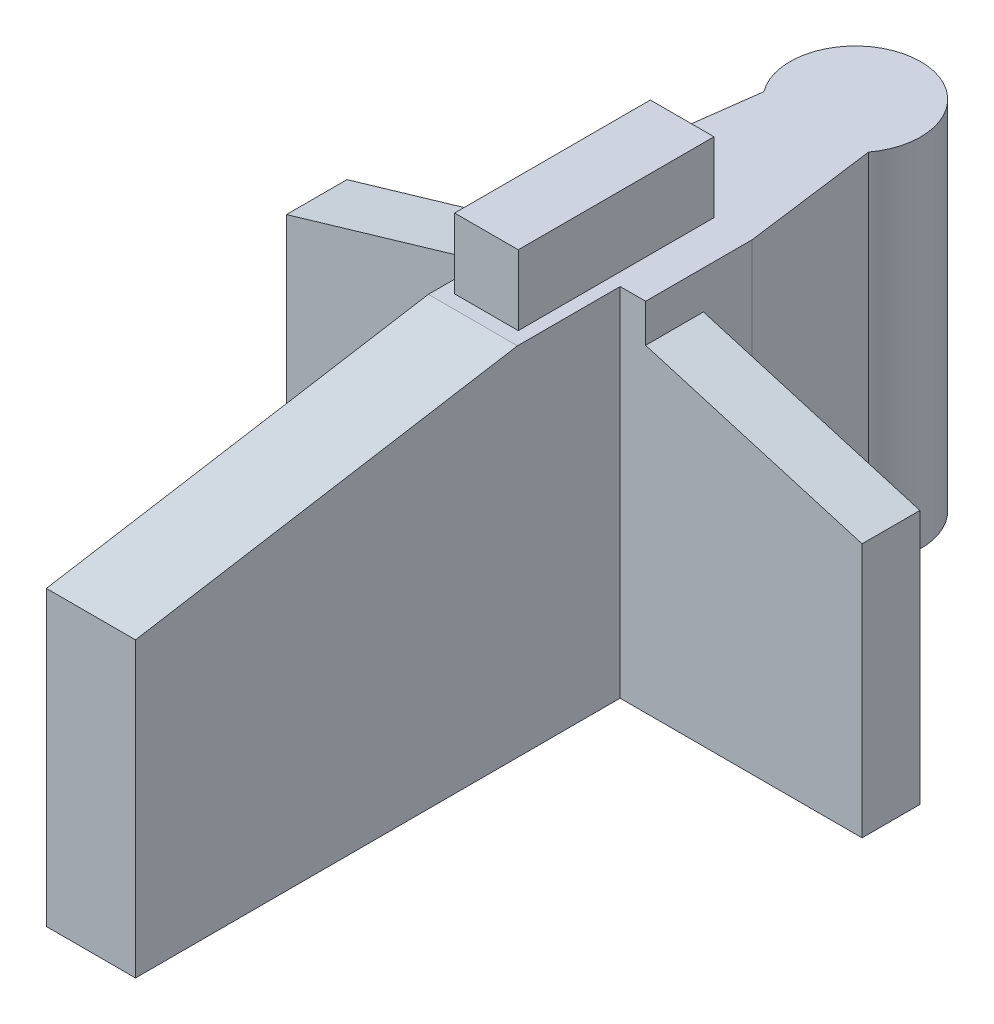
from build123d import *

# Parameters (mm, degrees)
BOSS_EXTRUDE1_DEPTH = 28
BOSS_EXTRUDE2_DEPTH = 5.5
CUT_EXTRUDE1_DEPTH  = 5.5
CUT_EXTRUDE2_DEPTH  = 8


with BuildPart() as part:
    # Sketch2 → Boss-Extrude1 (new body)
    with BuildSketch(Plane(origin=(0, 0, 0), x_dir=(1, 0, 0), z_dir=(0, 1, 0))):
        with BuildLine():
            Line((-248.771987083, 683.890458256), (-250.163612926, 673.36336753))
            Line((-250.163612926, 673.36336753), (-250.163612926, 669.53336753))
            Line((-250.163612926, 669.53336753), (-267.163612926, 669.53336753))
            Line((-267.163612926, 669.53336753), (-267.163612926, 664.78336753))
            Line((-267.163612926, 664.78336753), (-248.163612926, 664.78336753))
            Line((-248.163612926, 664.78336753), (-248.163612926, 626.928572815))
            Line((-248.163612926, 626.928572815), (-244.663612926, 626.928572815))
            Line((-244.663612926, 626.928572815), (-241.163612926, 626.928572815))
            Line((-241.163612926, 626.928572815), (-241.163612926, 664.990338865))
            Line((-241.163612926, 664.990338865), (-222.163612926, 664.990338865))
            Line((-222.163612926, 664.990338865), (-222.163612926, 669.53336753))
            Line((-222.163612926, 669.53336753), (-239.163612926, 669.53336753))
            Line((-239.163612926, 669.53336753), (-239.163612926, 673.362411263))
            Line((-239.163612926, 673.362411263), (-240.55523877, 683.890458256))
            ThreePointArc((-240.55523877, 683.890458256), (-244.663612926, 692.093561911), (-248.771987083, 683.890458256))
        make_face()
    extrude(amount=BOSS_EXTRUDE1_DEPTH)

    # Sketch6 → Boss-Extrude2 (add)
    with BuildSketch(Plane(origin=(0, 28, 0), x_dir=(1, 0, 0), z_dir=(0, 1, 0))):
        Polygon((-244.663612926, 673.362889397), (-242.163612926, 673.362889397), (-242.163612926, 657.990338865), (-244.663612926, 657.990338865), (-247.163612926, 657.990338865), (-247.163612926, 673.36310673), align=None)
    extrude(amount=BOSS_EXTRUDE2_DEPTH)

    # Sketch8 → Cut-Extrude1 (cut)
    with BuildSketch(Plane(origin=(0, 0, -669.53336753), x_dir=(-1, 0, 0), z_dir=(0, 0, -1))):
        Polygon((267.163612926, 20), (250.163612926, 25), (250.163612926, 28), (267.163612926, 28), align=None)
        Polygon((222.163612926, 20), (222.163612926, 28), (239.163612926, 28), (239.163612926, 25), align=None)
    extrude(amount=-CUT_EXTRUDE1_DEPTH, mode=Mode.SUBTRACT)

    # Sketch9 → Cut-Extrude2 (cut)
    with BuildSketch(Plane.ZY.offset(248.163612926)):
        Polygon((-626.928572815, 28), (-626.928572815, 23), (-656.928572815, 28), align=None)
    extrude(amount=-CUT_EXTRUDE2_DEPTH, mode=Mode.SUBTRACT)


solid = part.part
